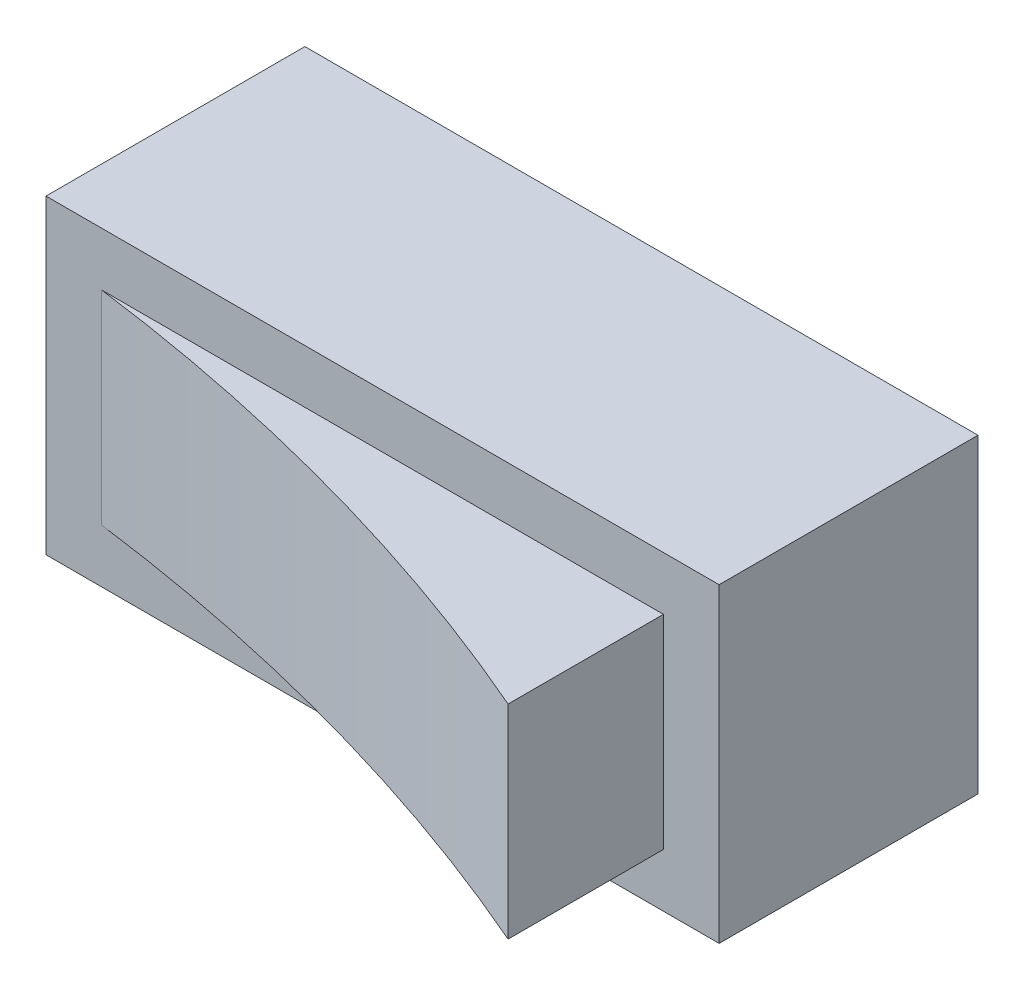
from build123d import *

# Parameters (mm, degrees)
SKETCH1_W           = 6.5
SKETCH1_H           = 2.5
BOSS_EXTRUDE1_DEPTH = 3
SKETCH2_W           = 5.424331786
SKETCH2_H           = 1.966345426
BOSS_EXTRUDE2_DEPTH = 1.5
CUT_EXTRUDE1_DEPTH  = 3.483172713


with BuildPart() as part:
    # Sketch1 → Boss-Extrude1 (new body)
    with BuildSketch(Plane(origin=(0, 0, 0), x_dir=(1, 0, 0), z_dir=(0, 1, 0))):
        Rectangle(SKETCH1_W, SKETCH1_H)
    extrude(amount=BOSS_EXTRUDE1_DEPTH)

    # Sketch2 → Boss-Extrude2 (add)
    with BuildSketch(Plane.XY.offset(1.25)):
        with Locations((0, 1.5)):
            Rectangle(SKETCH2_W, SKETCH2_H)
    extrude(amount=BOSS_EXTRUDE2_DEPTH)

    # Sketch4 → Cut-Extrude1 (cut, through all)
    with BuildSketch(Plane.XZ.offset(-0.516827287)):
        with BuildLine():
            Line((-2.712165893, 2.75), (2.712165893, 2.75))
            ThreePointArc((2.712165893, 2.75), (0.052459338, 1.810295429), (-2.712165893, 1.25))
            Line((-2.712165893, 1.25), (-2.712165893, 2.75))
        make_face()
    extrude(amount=-CUT_EXTRUDE1_DEPTH, mode=Mode.SUBTRACT)


solid = part.part
